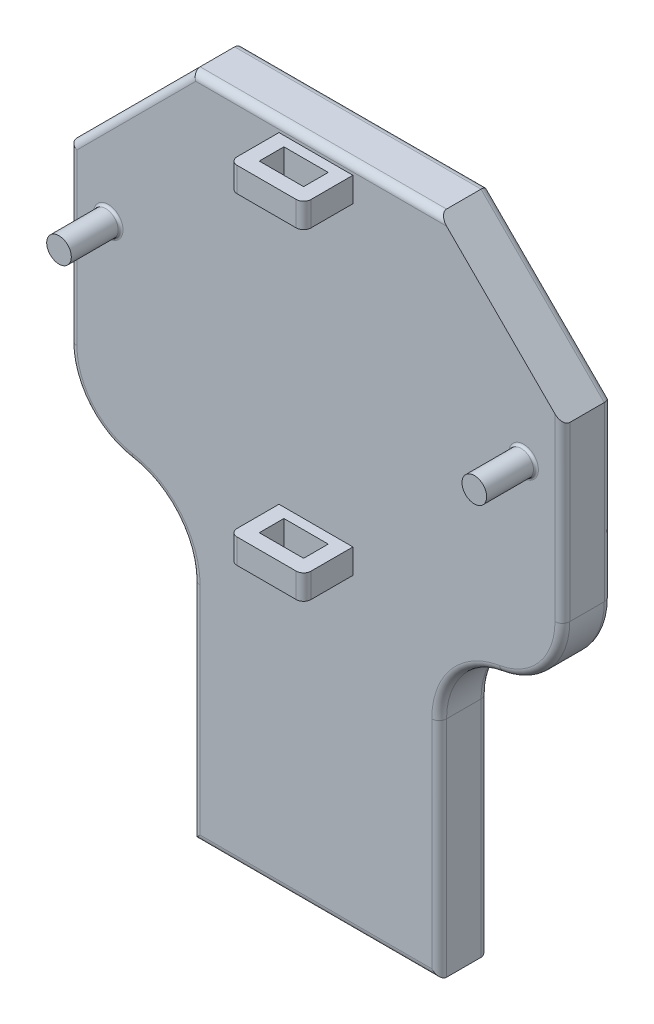
from build123d import *

# Parameters (mm, degrees)
BOSS_EXTRUDE1_DEPTH = 20
SKETCH2_R           = 5
BOSS_EXTRUDE2_DEPTH = 20
SKETCH3_W           = 200
SKETCH3_H           = 20
BOSS_EXTRUDE3_DEPTH = 50
SKETCH4_W           = 30
SKETCH4_H           = 10
BOSS_EXTRUDE4_DEPTH = 20
SKETCH5_W           = 18
SKETCH5_H           = 10
CUT_EXTRUDE1_DEPTH  = 145.75
SKETCH6_W           = 50
SKETCH6_H           = 20
BOSS_EXTRUDE5_DEPTH = 120
FILLET1_R           = 30
FILLET2_R           = 30
FILLET3_R           = 3
FILLET4_R           = 1


with BuildPart() as part:
    # Sketch1 → Boss-Extrude1 (new body)
    with BuildSketch(Plane.XY):
        Polygon((-100, 0), (-50, 50), (50, 50), (100, 0), (100, -50), (-100, -50), align=None)
    extrude(amount=BOSS_EXTRUDE1_DEPTH)

    # Sketch2 → Boss-Extrude2 (add)
    with BuildSketch(Plane.XY.offset(20)):
        with Locations((-84.27, -20)):
            Circle(SKETCH2_R)
        with Locations((84.27, -20)):
            Circle(SKETCH2_R)
    extrude(amount=BOSS_EXTRUDE2_DEPTH)

    # Sketch3 → Boss-Extrude3 (add)
    with BuildSketch(Plane.XZ.offset(50)):
        with Locations((0, 10)):
            Rectangle(SKETCH3_W, SKETCH3_H)
    extrude(amount=BOSS_EXTRUDE3_DEPTH)

    # Sketch4 → Boss-Extrude4 (add)
    with BuildSketch(Plane.XY.offset(20)):
        with Locations((0, -89.75)):
            Rectangle(SKETCH4_W, SKETCH4_H)
        with Locations((0, 40.86768586)):
            Rectangle(SKETCH4_W, SKETCH4_H)
    extrude(amount=BOSS_EXTRUDE4_DEPTH)

    # Sketch5 → Cut-Extrude1 (cut, through all)
    with BuildSketch(Plane.XZ.offset(94.75)):
        with Locations((0, 29)):
            Rectangle(SKETCH5_W, SKETCH5_H)
    extrude(amount=-CUT_EXTRUDE1_DEPTH, mode=Mode.SUBTRACT)

    # Sketch6 → Boss-Extrude5 (add)
    with BuildSketch(Plane.XZ.offset(100)):
        with Locations((-25, 10)):
            Rectangle(SKETCH6_W, SKETCH6_H)
        with Locations((25, 10)):
            Rectangle(SKETCH6_W, SKETCH6_H)
    extrude(amount=BOSS_EXTRUDE5_DEPTH)

    # Fillet1
    fillet1_edges = [part.edges().sort_by_distance(p)[0] for p in [
        (-100, -100, 10),
        (100, -100, 10),
    ]]
    fillet(fillet1_edges, radius=FILLET1_R)

    # Fillet2
    fillet2_edges = [part.edges().sort_by_distance(p)[0] for p in [
        (-50, -100, 10),
        (50, -100, 10),
    ]]
    fillet(fillet2_edges, radius=FILLET2_R)

    # Fillet3
    fillet3_edges = [part.edges().sort_by_distance(p)[0] for p in [
        (-50, -174.580398915, 20),
        (-50, -174.580398915, 0),
        (50, -174.580398915, 0),
        (50, -174.580398915, 20),
        (0, -220, 0),
        (0, -220, 20),
        (100, -35, 0),
        (92.912878475, -89.364916731, 0),
        (100, -35, 20),
        (-92.912878475, -89.364916731, 20),
        (0, 50, 20),
        (-92.912878475, -89.364916731, 0),
        (92.912878475, -89.364916731, 20),
        (-57.087121525, -109.7958811, 20),
        (-57.087121525, -109.7958811, 0),
        (57.087121525, -109.7958811, 0),
        (57.087121525, -109.7958811, 20),
        (-75, 25, 20),
        (-100, -35, 20),
        (15, -89.75, 40),
        (-15, -89.75, 40),
        (-15, 40.86768586, 40),
        (15, 40.86768586, 40),
        (-100, -35, 0),
        (-75, 25, 0),
        (0, 50, 0),
        (75, 25, 0),
    ]]
    fillet(fillet3_edges, radius=FILLET3_R)

    # Fillet4
    fillet4_edges = [part.edges().sort_by_distance(p)[0] for p in [
        (-89.27, -20, 20),
        (79.27, -20, 20),
    ]]
    fillet(fillet4_edges, radius=FILLET4_R)


solid = part.part
